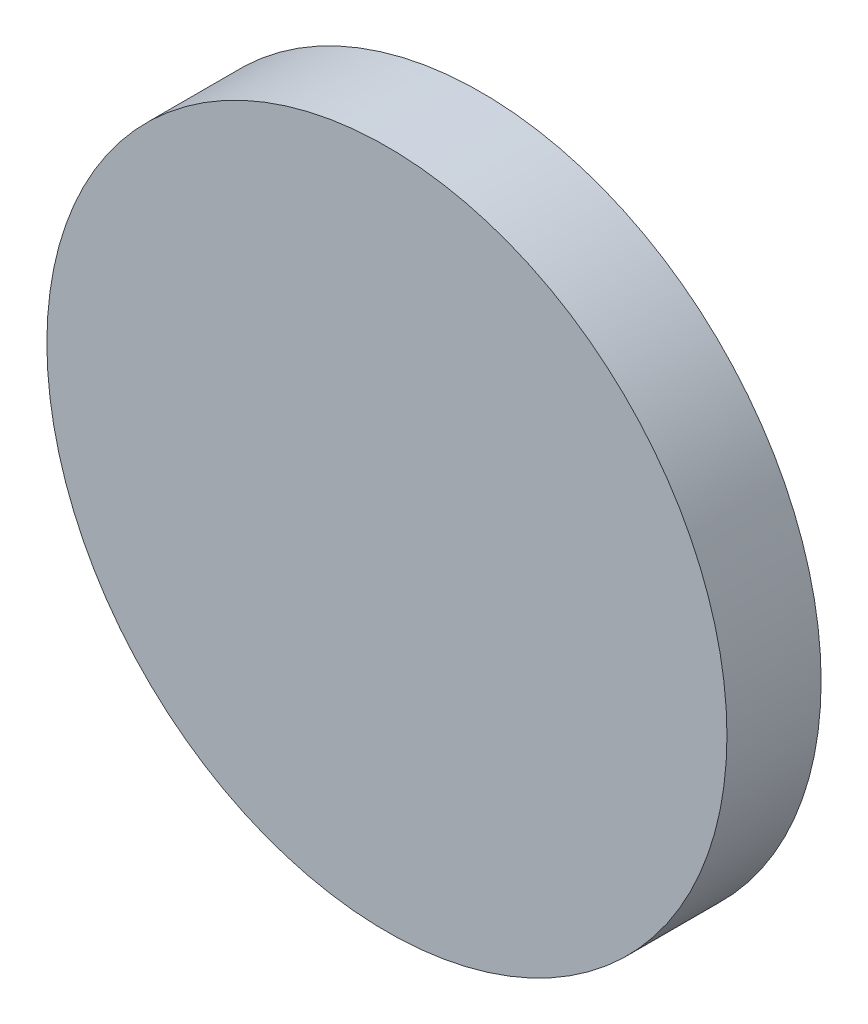
from build123d import *

# Parameters (mm, degrees)
SKIZZE1_R                       = 65
AUFSATZ_LINEAR_AUSTRAGEN1_DEPTH = 18


with BuildPart() as part:
    # Skizze1 → Aufsatz-Linear austragen1 (new body)
    with BuildSketch(Plane.XY):
        Circle(SKIZZE1_R)
    extrude(amount=AUFSATZ_LINEAR_AUSTRAGEN1_DEPTH)


solid = part.part
